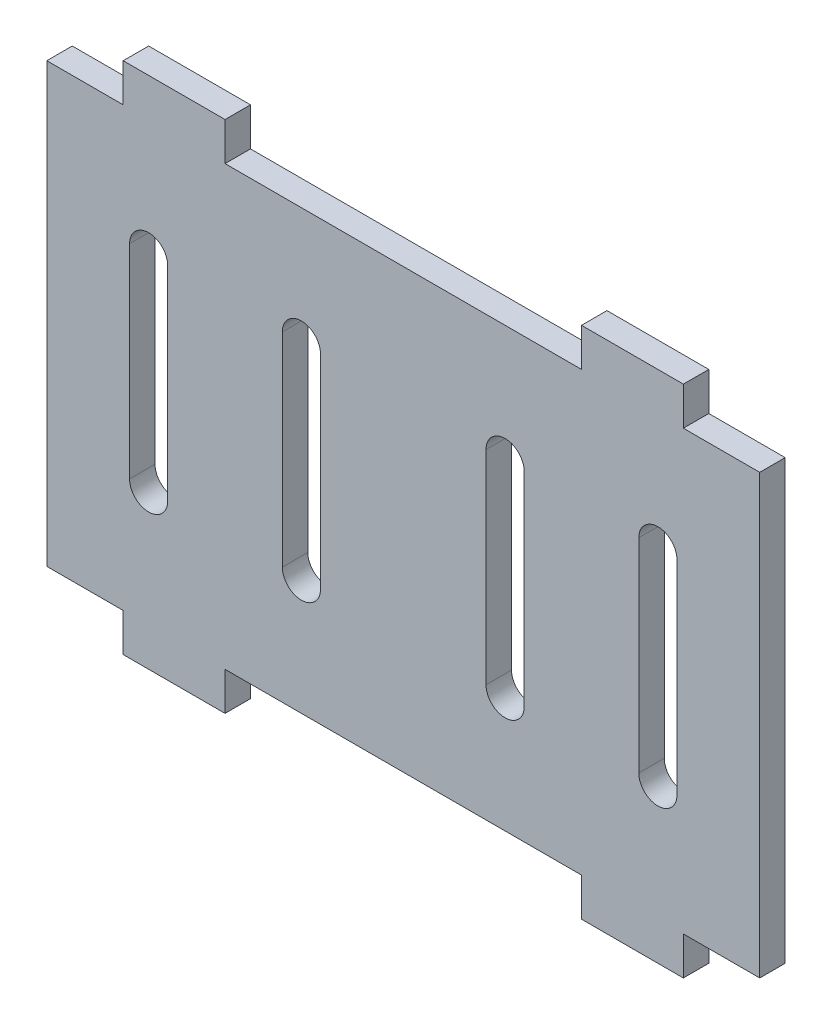
from build123d import *

# Parameters (mm, degrees)
SKETCH_1_W               = 56
SKETCH_1_H               = 34.4
EXTRUDE_1_DEPTH          = 2
SKETCH_2_W               = 8
SKETCH_2_H               = 2
EXTRUDE_2_DEPTH          = 6
MIRROR_2_COPY_1_SKETCH_W = 8
MIRROR_2_COPY_1_SKETCH_H = 2
MIRROR_2_COPY_1_DEPTH    = 6
EXTRUDE_3_DEPTH          = 8
EXTRUDE_4_DEPTH          = 8
EXTRUDE_5_DEPTH          = 8
CUT_EXTRUDE_1_DEPTH      = 10
SKETCH_8_W               = 69.954255789
SKETCH_8_H               = 15.282314342
SKETCH_8_W_2             = 75.120108524
SKETCH_8_H_2             = 7.103047511
CUT_EXTRUDE_3_DEPTH      = 2
CUT_EXTRUDE_3_DEPTH_BACK = 3


with BuildPart() as part:
    # 草图1 → 凸台-拉伸1 (new body)
    with BuildSketch(Plane.XY):
        Rectangle(SKETCH_1_W, SKETCH_1_H)
    extrude(amount=EXTRUDE_1_DEPTH)

    # 草图2 → 凸台-拉伸2 (add)
    with BuildSketch(Plane.XZ.offset(17.2)):
        with Locations((-18, 1)):
            Rectangle(SKETCH_2_W, SKETCH_2_H)
    extrude_2 = extrude(amount=EXTRUDE_2_DEPTH)

    # 镜向1: 凸台-拉伸2 across plane
    add(extrude_2.mirror(Plane.ZX))

    # 镜向2: 凸台-拉伸2 across plane
    add(extrude_2.mirror(Plane(origin=(0, 0, 0), x_dir=(0, 0, 1), z_dir=(1, 0, 0))))

    # 镜向2 copy 1 sketch → 镜向2 copy 1 (add)
    with BuildSketch(Plane(origin=(0, 17.2, 0), x_dir=(-1, 0, 0), z_dir=(0, 1, 0))):
        with Locations((-18, 1)):
            Rectangle(MIRROR_2_COPY_1_SKETCH_W, MIRROR_2_COPY_1_SKETCH_H)
    extrude(amount=MIRROR_2_COPY_1_DEPTH)

    # 草图4 → 凸台-拉伸3 (add)
    with BuildSketch(Plane(origin=(-14, 0, 0), x_dir=(0, 0, -1), z_dir=(1, 0, 0))):
        Polygon((-2, -23.2), (-2, -21.7), (-3, -21.7), align=None)
    extrude(amount=-EXTRUDE_3_DEPTH)

    # 草图5 → 凸台-拉伸4 (add)
    with BuildSketch(Plane(origin=(22, 0, 0), x_dir=(0, 0, -1), z_dir=(1, 0, 0))):
        Polygon((-2, -21.7), (-3, -21.7), (-2, -23.2), align=None)
        Polygon((-2, 23.2), (-2, 21.7), (-3, 21.7), align=None)
    extrude(amount=-EXTRUDE_4_DEPTH)

    # 草图6 → 凸台-拉伸5 (add)
    with BuildSketch(Plane(origin=(-14, 0, 0), x_dir=(0, 0, -1), z_dir=(1, 0, 0))):
        Polygon((-2, 23.2), (-2, 21.7), (-3, 21.7), align=None)
    extrude(amount=-EXTRUDE_5_DEPTH)

    # 草图7 → 切除-拉伸1 (cut)
    with BuildSketch(Plane.XY.offset(2)):
        with BuildLine():
            Line((-9.5, -8), (-9.5, 8))
            ThreePointArc((-9.5, 8), (-8, 9.5), (-6.5, 8))
            Line((-6.5, 8), (-6.5, -8))
            ThreePointArc((-6.5, -8), (-8, -9.5), (-9.5, -8))
        make_face()
        with BuildLine():
            Line((-21.5, -8), (-21.5, 8))
            ThreePointArc((-21.5, 8), (-20, 9.5), (-18.5, 8))
            Line((-18.5, 8), (-18.5, -8))
            ThreePointArc((-18.5, -8), (-20, -9.5), (-21.5, -8))
        make_face()
        with BuildLine():
            Line((6.5, -8), (6.5, 8))
            ThreePointArc((6.5, 8), (8, 9.5), (9.5, 8))
            Line((9.5, 8), (9.5, -8))
            ThreePointArc((9.5, -8), (8, -9.5), (6.5, -8))
        make_face()
        with BuildLine():
            Line((21.5, -8), (21.5, 8))
            ThreePointArc((21.5, 8), (20, 9.5), (18.5, 8))
            Line((18.5, 8), (18.5, -8))
            ThreePointArc((18.5, -8), (20, -9.5), (21.5, -8))
        make_face()
    extrude(amount=-CUT_EXTRUDE_1_DEPTH, mode=Mode.SUBTRACT)

    # 草图8 → 切除-拉伸3 (cut, two sides)
    with BuildSketch(Plane.XY.offset(2)) as cut_extrude_3_sk:
        with Locations((4.63474967, 27.841157171)):
            Rectangle(SKETCH_8_W, SKETCH_8_H)
        with Locations((-0.3158592, -23.751523756)):
            Rectangle(SKETCH_8_W_2, SKETCH_8_H_2)
    extrude(amount=CUT_EXTRUDE_3_DEPTH, mode=Mode.SUBTRACT)
    extrude(cut_extrude_3_sk.sketch, amount=-CUT_EXTRUDE_3_DEPTH_BACK, mode=Mode.SUBTRACT)


solid = part.part
